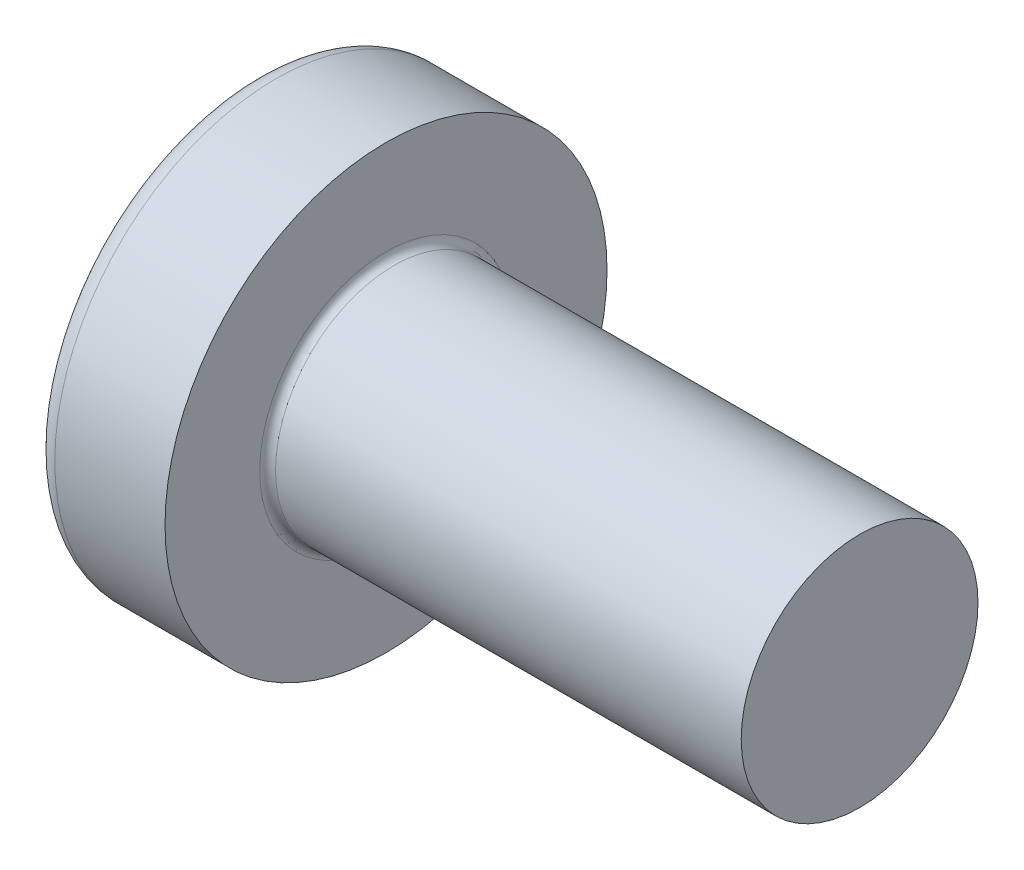
from build123d import *

# Parameters (mm, degrees)
FILLET1_R    = 0.1
SKETCH3_W    = 0.74
SKETCH3_H    = 2.8
SKETCH4_W    = 0.74
SKETCH4_H    = 1.054964432
RECPAT_COUNT = 2
RECPAT_ANGLE = 90


with BuildPart() as part:
    # BodySke → Base-Revolve (revolve)
    with BuildSketch(Plane.XY, mode=Mode.PRIVATE) as base_revolve_sk:
        with BuildLine():
            Line((2.4, 1.5), (2.4, 2.8))
            Line((2.4, 2.8), (1.003501533, 2.8))
            ThreePointArc((1.003501533, 2.8), (0.873295971, 2.76653015), (0.775371599, 2.674418605))
            ThreePointArc((0.775371599, 2.674418605), (0.197753546, 1.392274756), (0, 0))
            Line((0, 0), (8.4, 0))
            Line((8.4, 0), (8.4, 1.5))
            Line((8.4, 1.5), (2.4, 1.5))
        make_face()
    revolve(base_revolve_sk.sketch.rotate(Axis((-25.4, 0, 0), (1, 0, 0)), 90), axis=Axis((-25.4, 0, 0), (1, 0, 0)))  # turned: the seam where the file's is

    # Fillet1
    fillet1_edges = [part.edges().sort_by_distance(p)[0] for p in [
        (2.4, 0, -1.5),
    ]]
    fillet(fillet1_edges, radius=FILLET1_R)

    # Sketch3 → Recess section 0
    with BuildSketch(Plane(origin=(0, 0, 0), x_dir=(0, 0, -1), z_dir=(1, 0, 0))):
        Rectangle(SKETCH3_W, SKETCH3_H)
    # Sketch4 → Recess section 1
    with BuildSketch(Plane(origin=(1.75, 0, 0), x_dir=(0, 0, -1), z_dir=(1, 0, 0))):
        Rectangle(SKETCH4_W, SKETCH4_H)
    recess = loft(mode=Mode.SUBTRACT)

    # RecPat: Recess ×2 about axis
    recpat_axis = Axis((0, 0, 0), (1, 0, 0))
    for i in range(1, RECPAT_COUNT):
        add(recess.rotate(recpat_axis, i * RECPAT_ANGLE / (RECPAT_COUNT - 1)), mode=Mode.SUBTRACT)

    # RecCorSke → RecessCore (revolve, cut)
    with BuildSketch(Plane.XY, mode=Mode.PRIVATE) as recesscore_sk:
        Polygon((0, 0), (0, 0.678371921), (1.75, 0.556), (1.930655351, 0), align=None)
    revolve(recesscore_sk.sketch.rotate(Axis((-3.175, 0, 0), (1, 0, 0)), 90), axis=Axis((-3.175, 0, 0), (1, 0, 0)), mode=Mode.SUBTRACT)  # turned: the seam where the file's is


solid = part.part
